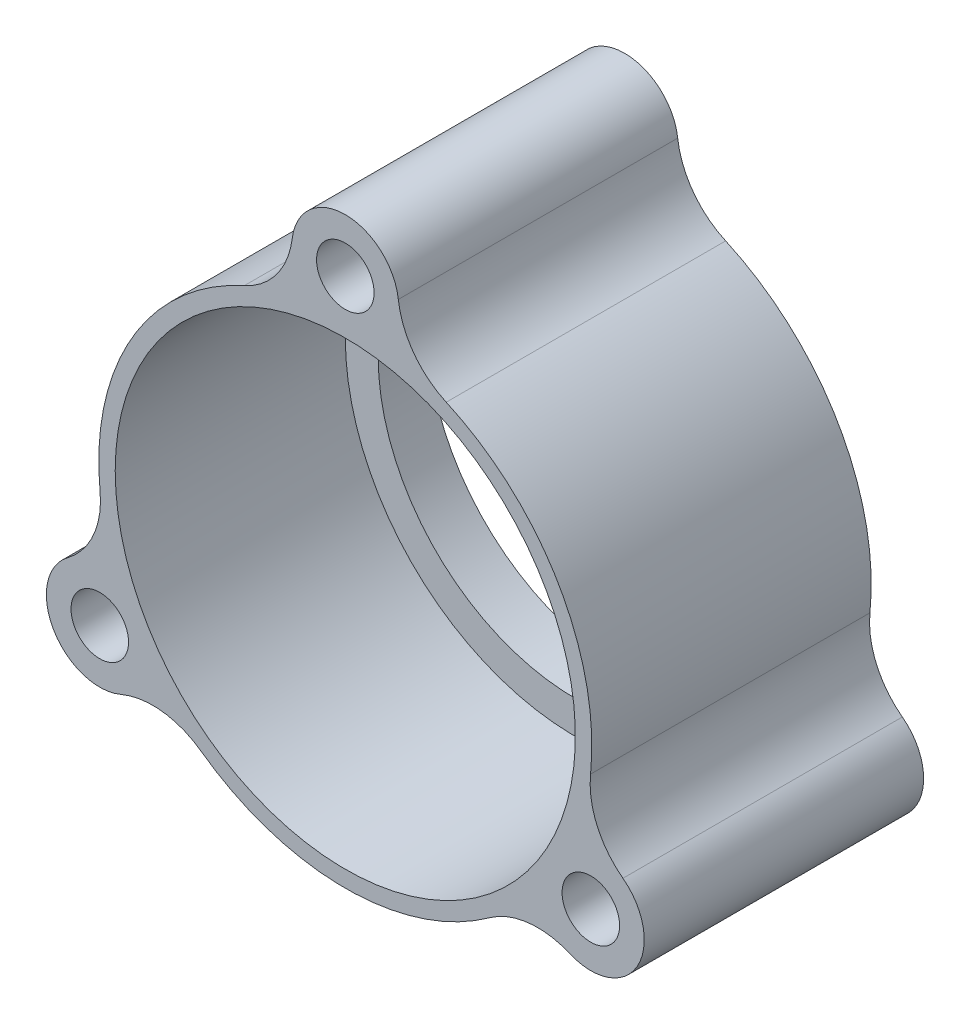
from build123d import *

# Parameters (mm, degrees)
SKETCH1_R                = 15
BOSS_EXTRUDE1_DEPTH      = 14
SKETCH4_R                = 14
CUT_EXTRUDE1_DEPTH       = 15
SKETCH3_R                = 15
SKETCH3_R_2              = 12
BOSS_EXTRUDE2_DEPTH      = 3
SKETCH6_R                = 3.25
SKETCH6_R_2              = 1.75
BOSS_EXTRUDE4_DEPTH      = 17
FILLET1_R                = 5
CIRPATTERN2_COUNT        = 3
FILLET1_OF_CIRPATTERN2_R = 5


with BuildPart() as part:
    # Sketch1 → Boss-Extrude1 (new body)
    with BuildSketch(Plane.XY):
        Circle(SKETCH1_R)
    extrude(amount=BOSS_EXTRUDE1_DEPTH)

    # Sketch4 → Cut-Extrude1 (cut, through all)
    with BuildSketch(Plane(origin=(0, 0, 0), x_dir=(-1, 0, 0), z_dir=(0, 0, -1))):
        Circle(SKETCH4_R)
    extrude(amount=-CUT_EXTRUDE1_DEPTH, mode=Mode.SUBTRACT)

    # Sketch3 → Boss-Extrude2 (add)
    with BuildSketch(Plane(origin=(0, 0, 0), x_dir=(-1, 0, 0), z_dir=(0, 0, -1))):
        Circle(SKETCH3_R)
        Circle(SKETCH3_R_2, mode=Mode.SUBTRACT)
    extrude(amount=BOSS_EXTRUDE2_DEPTH)

    # Sketch6 → Boss-Extrude4 (add)
    with BuildSketch(Plane.XY.offset(14)):
        with Locations((0, 17.25)):
            Circle(SKETCH6_R)
        with Locations((0, 17.25)):
            Circle(SKETCH6_R_2, mode=Mode.SUBTRACT)
    boss_extrude4 = extrude(amount=-BOSS_EXTRUDE4_DEPTH)

    # Fillet1
    fillet1_edges = [part.edges().sort_by_distance(p)[0] for p in [
        (2.181099234, 14.84057971, 7),
        (-2.181099234, 14.84057971, 7),
    ]]
    fillet(fillet1_edges, radius=FILLET1_R)

    # CirPattern2: Boss-Extrude4 ×3 about axis
    cirpattern2_axis = Axis((0, 0, 0), (0, 0, 1))
    for i in range(1, CIRPATTERN2_COUNT):
        add(boss_extrude4.rotate(cirpattern2_axis, i * 360 / CIRPATTERN2_COUNT))

    # Fillet1 of CirPattern2
    fillet1_of_cirpattern2_edges = [part.edges().sort_by_distance(p)[0] for p in [
        (-13.942868653, -5.531402511, 7),
        (-11.761769419, -9.3091772, 7),
        (11.761769419, -9.3091772, 7),
        (13.942868653, -5.531402511, 7),
    ]]
    fillet(fillet1_of_cirpattern2_edges, radius=FILLET1_OF_CIRPATTERN2_R)


solid = part.part
